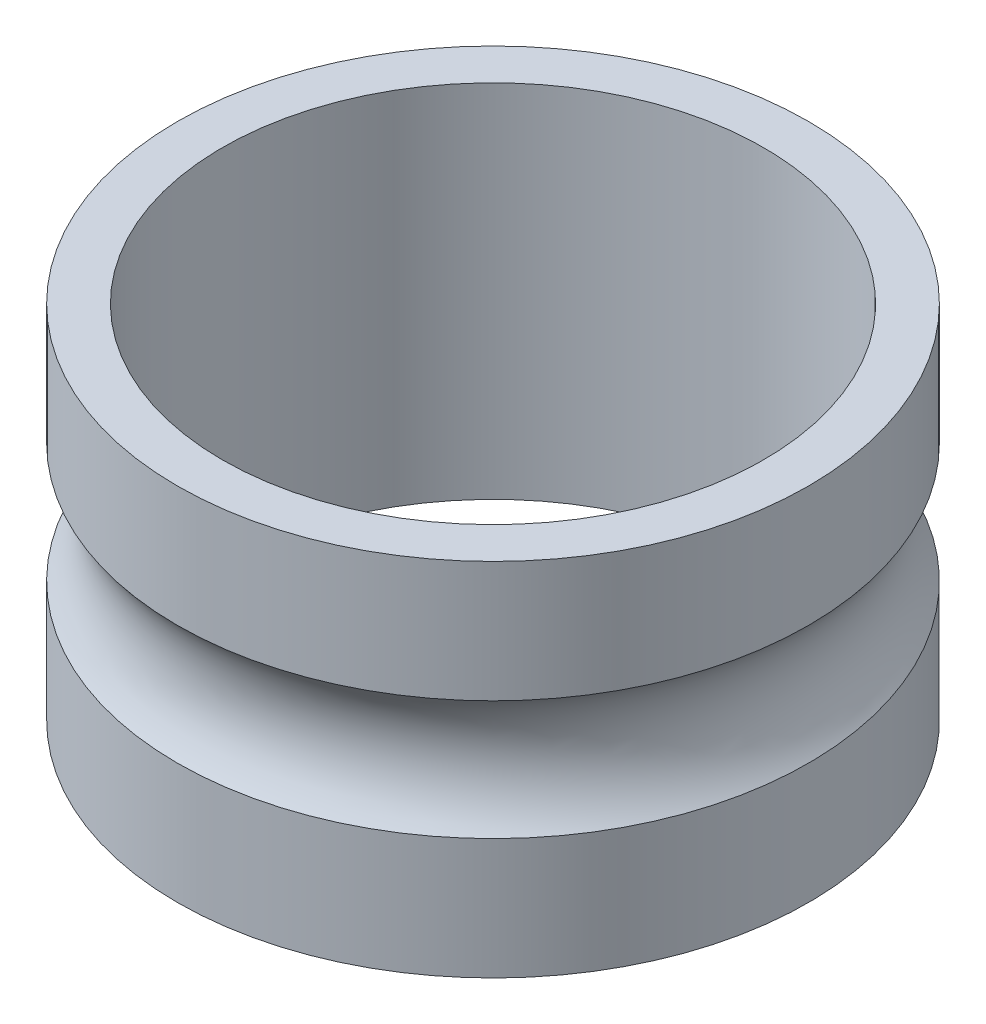
from build123d import *

# Parameters (mm, degrees)
DIAPROFILES_R         = 1.75
DIAPROFILES_R_2       = 1.5
DIAPROFILE_DEPTH      = 1
BEARINGPATHPROFILES_R = 0.5


with BuildPart() as part:
    # DiaProfileS → DiaProfile (new body, symmetric)
    with BuildSketch(Plane(origin=(0, 0, 0), x_dir=(1, 0, 0), z_dir=(0, 1, 0))):
        Circle(DIAPROFILES_R)
        Circle(DIAPROFILES_R_2, mode=Mode.SUBTRACT)
    extrude(amount=DIAPROFILE_DEPTH, both=True)

    # BearingPathProfileS → BearingPathProfile (revolve, cut)
    with BuildSketch(Plane.XY):
        with Locations((2.125, 0)):
            Circle(BEARINGPATHPROFILES_R)
    revolve(axis=Axis((0, 1, 0), (0, -1, 0)), mode=Mode.SUBTRACT)


solid = part.part
